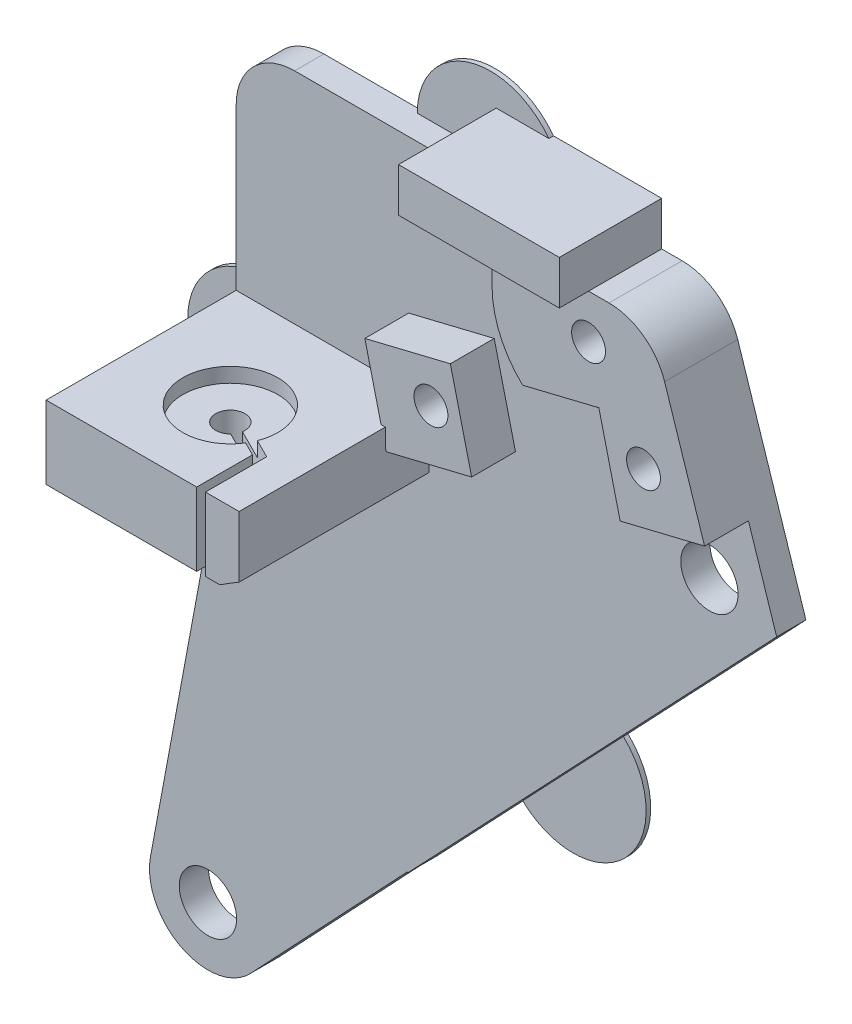
from build123d import *

# Parameters (mm, degrees)
SKETCH2_R                = 3.81
BOSS_EXTRUDE1_DEPTH      = 2.54
SKETCH5_W                = 16.764
SKETCH5_H                = 6.35
BOSS_EXTRUDE2_DEPTH      = 16.51
SKETCH6_R                = 4.1275
CUT_EXTRUDE2_DEPTH       = 1.27
SKETCH7_R                = 1.27
CUT_EXTRUDE3_DEPTH       = 65.77
CUT_EXTRUDE4_DEPTH       = 2.286
BOSS_EXTRUDE3_DEPTH      = 3.81
F_4_CLEARANCE_HOLE1_D    = 2.9464
SKETCH14_W               = 13.97
SKETCH14_H               = 3.81
BOSS_EXTRUDE6_DEPTH      = 6.35
BOSS_EXTRUDE6_DEPTH_BACK = 2.54
FILLET1_R                = 5.08
CUT_EXTRUDE5_DEPTH       = 17.51
CUT_EXTRUDE5_DEPTH_BACK  = 3.54
SKETCH19_R               = 2.4892
BOSS_EXTRUDE8_DEPTH      = 2.54
CUT_EXTRUDE8_DEPTH       = 2.54
CUT_EXTRUDE9_DEPTH       = 53.355501773
SKETCH13_R               = 6.35
PRINT_TABS_DEPTH         = 0.4


with BuildPart() as part:
    # Sketch2 → Boss-Extrude1 (new body)
    with BuildSketch(Plane.XY):
        with BuildLine():
            Line((-17.068825413, -8.459178389), (-41.402, 40.64))
            Line((-41.402, 40.64), (-41.402, 66.04))
            Line((-41.402, 66.04), (-1.524, 66.04))
            Line((-1.524, 66.04), (18.109053667, 5.913093546))
            ThreePointArc((18.109053667, 5.913093546), (7.204933647, -17.634949139), (-17.068825413, -8.459178389))
        make_face()
        Circle(SKETCH2_R, mode=Mode.SUBTRACT)
    extrude(amount=BOSS_EXTRUDE1_DEPTH)

    # Sketch5 → Boss-Extrude2 (add)
    with BuildSketch(Plane.XY.offset(2.54)):
        with Locations((-33.02, 43.815)):
            Rectangle(SKETCH5_W, SKETCH5_H)
    extrude(amount=BOSS_EXTRUDE2_DEPTH)

    # Sketch6 → Cut-Extrude2 (cut)
    with BuildSketch(Plane(origin=(0, 46.99, 0), x_dir=(1, 0, 0), z_dir=(0, 1, 0))):
        with Locations((-33.02, -11.43)):
            Circle(SKETCH6_R)
    extrude(amount=-CUT_EXTRUDE2_DEPTH, mode=Mode.SUBTRACT)

    # Sketch7 → Cut-Extrude3 (cut, through all)
    with BuildSketch(Plane(origin=(0, 45.72, 0), x_dir=(1, 0, 0), z_dir=(0, 1, 0))):
        with Locations((-33.02, -11.43)):
            Circle(SKETCH7_R)
    extrude(amount=-CUT_EXTRUDE3_DEPTH, mode=Mode.SUBTRACT)

    # Sketch9 → Cut-Extrude4 (cut)
    with BuildSketch(Plane(origin=(0, 0, 0), x_dir=(-1, 0, 0), z_dir=(0, 0, -1))):
        Polygon((3.171122265, 62.23), (5.077532854, 58.928), (8.890354032, 58.928), (10.796764621, 62.23), (8.890354032, 65.532), (5.077532854, 65.532), align=None)
        Polygon((24.379877895, 49.663956202), (23.308143816, 53.323053276), (19.603405755, 54.224452874), (16.970401774, 51.466755398), (18.042135853, 47.807658324), (21.746873914, 46.906258726), align=None)
        Polygon((5.918476139, 54.15579827), (4.846742059, 57.814895344), (1.142003999, 58.716294942), (-1.490999983, 55.958597466), (-0.419265903, 52.299500392), (3.285472157, 51.398100794), align=None)
    extrude(amount=-CUT_EXTRUDE4_DEPTH, mode=Mode.SUBTRACT)

    # Sketch8 → Boss-Extrude3 (add)
    with BuildSketch(Plane.XY.offset(2.54)):
        with BuildLine():
            Line((-15.367, 66.04), (-6.983943443, 66.04))
            Line((-6.983943443, 66.04), (-1.524, 66.04))
            Line((-1.524, 66.04), (3.09175139, 51.904101595))
            Line((3.09175139, 51.904101595), (-4.240438106, 50.120107003))
            Line((-4.240438106, 50.120107003), (-6.088713216, 57.716488409))
            Line((-6.088713216, 57.716488409), (-12.708473154, 56.10583501))
            ThreePointArc((-12.708473154, 56.10583501), (-14.673699407, 58.891843255), (-15.367, 62.23))
            Line((-15.367, 62.23), (-15.367, 66.04))
        make_face()
        Polygon((-17.142042414, 46.981018422), (-18.990317524, 54.577399829), (-26.415687706, 52.770733449), (-24.567412596, 45.174352043), align=None)
    extrude(amount=BOSS_EXTRUDE3_DEPTH)

    # #4 Clearance Hole1 (through all)
    with Locations(Plane.XY.offset(6.35)):
        with Locations((-6.983943443, 62.23), (-20.675139834, 50.5653558), (-2.213738078, 55.057197868)):
            Hole(F_4_CLEARANCE_HOLE1_D / 2)

    # Sketch14 → Boss-Extrude6 (add, two sides)
    with BuildSketch(Plane.XY.offset(2.54)) as boss_extrude6_sk:
        with Locations((-13.968943443, 67.945)):
            Rectangle(SKETCH14_W, SKETCH14_H)
    extrude(amount=BOSS_EXTRUDE6_DEPTH)
    extrude(boss_extrude6_sk.sketch, amount=-BOSS_EXTRUDE6_DEPTH_BACK)

    # Fillet1
    fillet1_edges = [part.edges().sort_by_distance(p)[0] for p in [
        (-1.524, 66.04, 3.175),
        (-41.402, 66.04, 1.27),
    ]]
    fillet(fillet1_edges, radius=FILLET1_R)

    # Sketch15 → Cut-Extrude5 (cut, two sides)
    with BuildSketch(Plane.XY.offset(2.54)) as cut_extrude5_sk:
        with BuildLine():
            ThreePointArc((-0.315167053, 48.411374113), (-18.310138041, 44.816284079), (-33.674369734, 34.782140486))
            ThreePointArc((-33.674369734, 34.782140486), (-33.731327517, 31.262340905), (-30.211527936, 31.205383122))
            ThreePointArc((-30.211527936, 31.205383122), (-16.427248714, 40.207684038), (-0.28275743, 43.433079608))
            ThreePointArc((-0.28275743, 43.433079608), (2.190185011, 45.938431672), (-0.315167053, 48.411374113))
        make_face()
    extrude(amount=CUT_EXTRUDE5_DEPTH, mode=Mode.SUBTRACT)
    extrude(cut_extrude5_sk.sketch, amount=-CUT_EXTRUDE5_DEPTH_BACK, mode=Mode.SUBTRACT)

    # Sketch19 → Boss-Extrude8 (add, through all)
    with BuildSketch(Plane.XY.offset(2.54)):
        with BuildLine():
            Line((5.466200245, 44.632269783), (-40.158007355, -3.769954845))
            ThreePointArc((-40.158007355, -3.769954845), (-46.15516131, -4.814733016), (-48.848797168, 0.64436424))
            Line((-48.848797168, 0.64436424), (-41.402, 40.64))
            Line((-41.402, 40.64), (3.09175139, 51.904101595))
            Line((3.09175139, 51.904101595), (5.466200245, 44.632269783))
        make_face()
        with Locations((-0.298962241, 45.92222686)):
            Circle(SKETCH19_R, mode=Mode.SUBTRACT)
        with Locations((-43.854625645, -0.285501773)):
            Circle(SKETCH19_R, mode=Mode.SUBTRACT)
    extrude(amount=-BOSS_EXTRUDE8_DEPTH)

    # Sketch20 → Cut-Extrude8 (cut)
    with BuildSketch(Plane.XY.offset(2.54)):
        Polygon((-40.158007355, -3.769954845), (10.729493517, 49.863783044), (48.07174347, 14.433588323), (-7.673080914, -44.319607422), align=None)
    extrude(amount=-CUT_EXTRUDE8_DEPTH, mode=Mode.SUBTRACT)

    # Sketch21 → Cut-Extrude9 (cut, through all)
    with BuildSketch(Plane(origin=(0, 46.99, 0), x_dir=(1, 0, 0), z_dir=(0, 1, 0))):
        Polygon((-27.559, -19.05), (-27.559, -13.73452905), (-32.84961162, -11.08922324), (-33.19038838, -11.77077676), (-28.321, -14.20547095), (-28.321, -19.05), align=None)
    extrude(amount=-CUT_EXTRUDE9_DEPTH, mode=Mode.SUBTRACT)

    # Sketch13 → Print Tabs (add)
    with BuildSketch(Plane(origin=(0, 0, 0), x_dir=(-1, 0, 0), z_dir=(0, 0, -1))):
        with Locations((14.284313144, 23.500060577)):
            Circle(SKETCH13_R)
        with Locations((21.463, 66.04)):
            Circle(SKETCH13_R)
        with Locations((41.402, 40.64)):
            Circle(SKETCH13_R)
    extrude(amount=-PRINT_TABS_DEPTH)


solid = part.part
